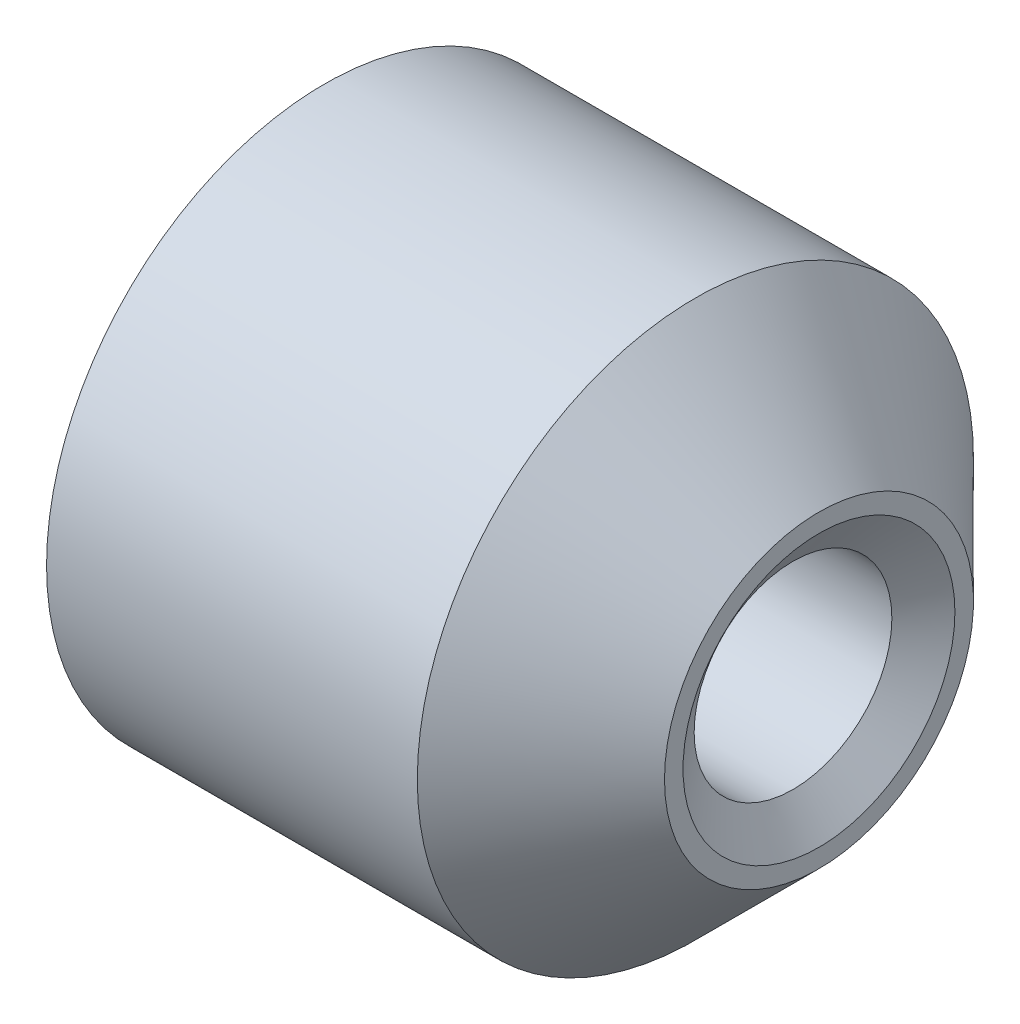
from build123d import *


with BuildPart() as part:
    # Эскиз1 → Повернуть1 (revolve)
    with BuildSketch(Plane.XY):
        Polygon((0, 0.8), (0, 2.25), (3, 2.25), (4, 1.25), (4, 0.8), align=None)
    revolve(axis=Axis((0, 0, 0), (1, 0, 0)))

    # Эскиз2 → Отверстие обработанное метчиком M2x0.41 (revolve, cut)
    with BuildSketch(Plane(origin=(4, 0, 0), x_dir=(0, 0, -1), z_dir=(0, 1, 0))):
        Polygon((0, 0), (0, 4), (1.1, 4), (0.8, 3.789937739), (0.8, 0.210062261), (1.1, 0), align=None)
    revolve(axis=Axis((10.35, 0, 0), (-1, 0, 0)), mode=Mode.SUBTRACT)


solid = part.part
